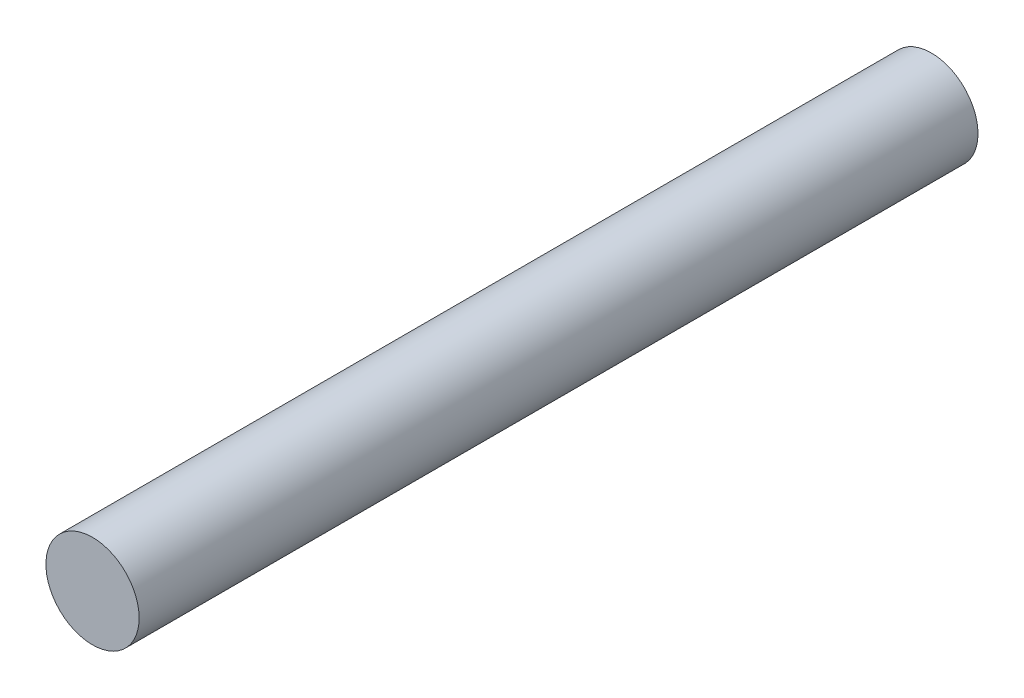
from build123d import *

# Parameters (mm, degrees)
SKETCH_1_R      = 1
EXTRUDE_1_DEPTH = 18


with BuildPart() as part:
    # 草图1 → 凸台-拉伸1 (new body)
    with BuildSketch(Plane.XY):
        Circle(SKETCH_1_R)
    extrude(amount=EXTRUDE_1_DEPTH)


solid = part.part
